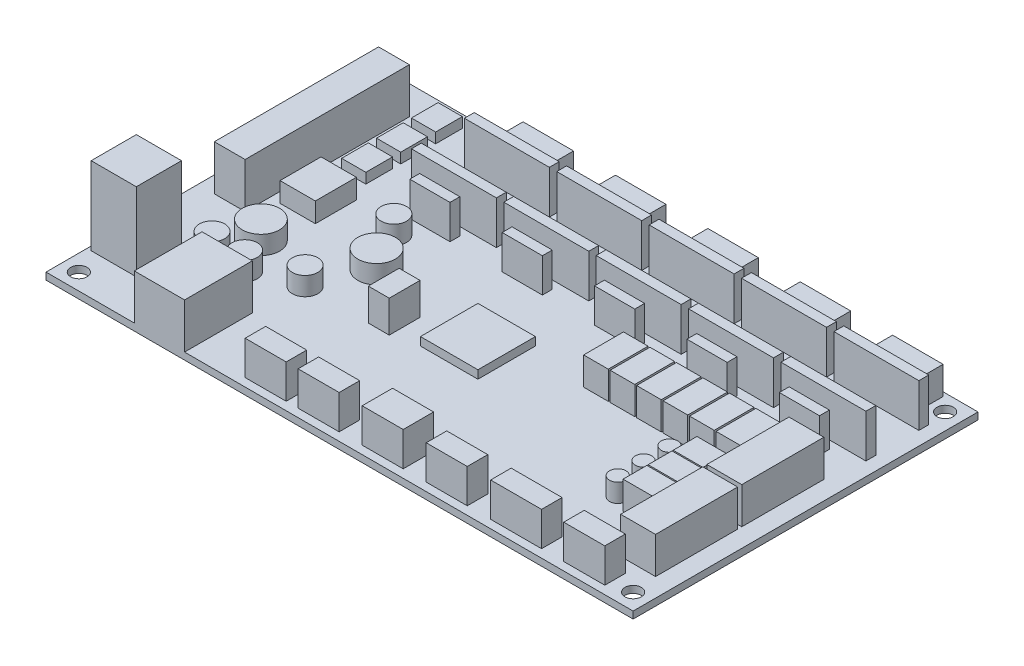
from build123d import *

# Parameters (mm, degrees)
PCB_W                     = 143
PCB_H                     = 84
PCB_R                     = 2
BOSS_PCB_DEPTH            = 1.7
BLUECONNECTOR_W           = 7.5
BLUECONNECTOR_H           = 40
BOSS_BLUECONNECTOR_DEPTH  = 11
GREENCONNECTOR_W          = 11
GREENCONNECTOR_H          = 11
BOSS_GREENCONNECTOR_DEPTH = 19
USB_W                     = 12.25
USB_H                     = 16.5
BOSS_USB_DEPTH            = 11
DRIVERSOCKETS_W           = 20.7
DRIVERSOCKETS_H           = 2.4
BOSS_DRIVERSOCKETS_DEPTH  = 10.5
NEMASOCKETS_W             = 12.3
NEMASOCKETS_H             = 5.7
BOSS_NEMASOCKETS_DEPTH    = 6.8
SKETCH2_W                 = 8.5
SKETCH2_H                 = 20
BOSS_EXTRUDE2_DEPTH       = 8.9
SKETCH3_W                 = 6
SKETCH3_H                 = 9.7
BOSS_EXTRUDE3_DEPTH       = 6.8
SKETCH4_W                 = 7.25
SKETCH4_H                 = 5.8
BOSS_EXTRUDE4_DEPTH       = 6.8
SKETCH5_R                 = 2
SKETCH5_R_2               = 3.1
SKETCH5_R_3               = 4.581614288
SKETCH5_R_4               = 4.548835819
BOSS_EXTRUDE5_DEPTH       = 4.5
SKETCH6_W                 = 5.9
SKETCH6_H                 = 6.5
BOSS_EXTRUDE6_DEPTH       = 2.5
SKETCH7_W                 = 8.6
SKETCH7_H                 = 10
BOSS_EXTRUDE7_DEPTH       = 4.8
SKETCH8_W                 = 5.1
SKETCH8_H                 = 7.5
BOSS_EXTRUDE8_DEPTH       = 7.8
SKETCH9_W                 = 14
SKETCH9_H                 = 14
BOSS_EXTRUDE9_DEPTH       = 2
SKETCH10_W                = 10
SKETCH10_H                = 5
SKETCH10_H_2              = 7.4
SKETCH10_W_2              = 12.4
BOSS_EXTRUDE10_DEPTH      = 8.3
SKETCH11_W                = 9.8
SKETCH11_H                = 2.4
BOSS_EXTRUDE11_DEPTH      = 8.3


with BuildPart() as part:
    # PCB → Boss-PCB (new body)
    with BuildSketch(Plane(origin=(0, 0, 0), x_dir=(1, 0, 0), z_dir=(0, 1, 0))):
        Rectangle(PCB_W, PCB_H)
        with Locations((-67.5, -38)):
            Circle(PCB_R, mode=Mode.SUBTRACT)
        with Locations((-67.5, 38)):
            Circle(PCB_R, mode=Mode.SUBTRACT)
        with Locations((67.5, -38)):
            Circle(PCB_R, mode=Mode.SUBTRACT)
        with Locations((67.5, 38)):
            Circle(PCB_R, mode=Mode.SUBTRACT)
    extrude(amount=BOSS_PCB_DEPTH)

    # BlueConnector → Boss-BlueConnector (add)
    with BuildSketch(Plane(origin=(0, 1.7, 0), x_dir=(1, 0, 0), z_dir=(0, 1, 0))):
        with Locations((-63.75, 15)):
            Rectangle(BLUECONNECTOR_W, BLUECONNECTOR_H)
    extrude(amount=BOSS_BLUECONNECTOR_DEPTH)

    # GreenConnector → Boss-GreenConnector (add)
    with BuildSketch(Plane(origin=(0, 1.7, 0), x_dir=(1, 0, 0), z_dir=(0, 1, 0))):
        with Locations((-65, -26.5)):
            Rectangle(GREENCONNECTOR_W, GREENCONNECTOR_H)
    extrude(amount=BOSS_GREENCONNECTOR_DEPTH)

    # Usb → Boss-Usb (add)
    with BuildSketch(Plane(origin=(0, 1.7, 0), x_dir=(1, 0, 0), z_dir=(0, 1, 0))):
        with Locations((-43.875, -33.75)):
            Rectangle(USB_W, USB_H)
    extrude(amount=BOSS_USB_DEPTH)

    # DriverSockets → Boss-DriverSockets (add)
    with BuildSketch(Plane(origin=(0, 1.7, 0), x_dir=(1, 0, 0), z_dir=(0, 1, 0))):
        with Locations((-32.15, 32.1)):
            Rectangle(DRIVERSOCKETS_W, DRIVERSOCKETS_H)
        with Locations((-32.15, 19.2)):
            Rectangle(DRIVERSOCKETS_W, DRIVERSOCKETS_H)
        with Locations((-9.65, 32.1)):
            Rectangle(DRIVERSOCKETS_W, DRIVERSOCKETS_H)
        with Locations((-9.65, 19.2)):
            Rectangle(DRIVERSOCKETS_W, DRIVERSOCKETS_H)
        with Locations((12.85, 32.1)):
            Rectangle(DRIVERSOCKETS_W, DRIVERSOCKETS_H)
        with Locations((12.85, 19.2)):
            Rectangle(DRIVERSOCKETS_W, DRIVERSOCKETS_H)
        with Locations((35.35, 32.1)):
            Rectangle(DRIVERSOCKETS_W, DRIVERSOCKETS_H)
        with Locations((35.35, 19.2)):
            Rectangle(DRIVERSOCKETS_W, DRIVERSOCKETS_H)
        with Locations((57.85, 32.1)):
            Rectangle(DRIVERSOCKETS_W, DRIVERSOCKETS_H)
        with Locations((57.85, 19.2)):
            Rectangle(DRIVERSOCKETS_W, DRIVERSOCKETS_H)
    extrude(amount=BOSS_DRIVERSOCKETS_DEPTH)

    # NemaSockets → Boss-NemaSockets (add)
    with BuildSketch(Plane(origin=(0, 1.7, 0), x_dir=(1, 0, 0), z_dir=(0, 1, 0))):
        with Locations((-32.15, 38.15)):
            Rectangle(NEMASOCKETS_W, NEMASOCKETS_H)
        with Locations((-9.65, 38.15)):
            Rectangle(NEMASOCKETS_W, NEMASOCKETS_H)
        with Locations((12.85, 38.15)):
            Rectangle(NEMASOCKETS_W, NEMASOCKETS_H)
        with Locations((35.35, 38.15)):
            Rectangle(NEMASOCKETS_W, NEMASOCKETS_H)
        with Locations((57.85, 38.15)):
            Rectangle(NEMASOCKETS_W, NEMASOCKETS_H)
    extrude(amount=BOSS_NEMASOCKETS_DEPTH)

    # Sketch2 → Boss-Extrude2 (add)
    with BuildSketch(Plane(origin=(0, 1.7, 0), x_dir=(1, 0, 0), z_dir=(0, 1, 0))):
        with Locations((62.711319294, -1)):
            Rectangle(SKETCH2_W, SKETCH2_H)
        with Locations((62.711319294, -22)):
            Rectangle(SKETCH2_W, SKETCH2_H)
    extrude(amount=BOSS_EXTRUDE2_DEPTH)

    # Sketch3 → Boss-Extrude3 (add)
    with BuildSketch(Plane(origin=(0, 1.7, 0), x_dir=(1, 0, 0), z_dir=(0, 1, 0))):
        with Locations((53.5, 4.05)):
            Rectangle(SKETCH3_W, SKETCH3_H)
        with Locations((47.05, 4.05)):
            Rectangle(SKETCH3_W, SKETCH3_H)
        with Locations((40.6, 4.05)):
            Rectangle(SKETCH3_W, SKETCH3_H)
        with Locations((34.15, 4.05)):
            Rectangle(SKETCH3_W, SKETCH3_H)
        with Locations((27.7, 4.05)):
            Rectangle(SKETCH3_W, SKETCH3_H)
        with Locations((21.25, 4.05)):
            Rectangle(SKETCH3_W, SKETCH3_H)
    extrude(amount=BOSS_EXTRUDE3_DEPTH)

    # Sketch4 → Boss-Extrude4 (add)
    with BuildSketch(Plane(origin=(0, 1.7, 0), x_dir=(1, 0, 0), z_dir=(0, 1, 0))):
        with Locations((52.875, -13.2)):
            Rectangle(SKETCH4_W, SKETCH4_H)
        with Locations((52.875, -7.1)):
            Rectangle(SKETCH4_W, SKETCH4_H)
        with Locations((52.875, -19.3)):
            Rectangle(SKETCH4_W, SKETCH4_H)
    extrude(amount=BOSS_EXTRUDE4_DEPTH)

    # Sketch5 → Boss-Extrude5 (add)
    with BuildSketch(Plane(origin=(0, 1.7, 0), x_dir=(1, 0, 0), z_dir=(0, 1, 0))):
        with Locations((45.532522997, -7.173614127)):
            Circle(SKETCH5_R)
        with Locations((45.532522997, -13.473614127)):
            Circle(SKETCH5_R)
        with Locations((45.532522997, -19.773614127)):
            Circle(SKETCH5_R)
        with Locations((-36.927915338, 8.153213954)):
            Circle(SKETCH5_R_2)
        with Locations((-55.386688385, -17.675511473)):
            Circle(SKETCH5_R_2)
        with Locations((-47.448627148, -17.675511473)):
            Circle(SKETCH5_R_2)
        with Locations((-36.927915338, -13.473614127)):
            Circle(SKETCH5_R_2)
        with Locations((-31.770956206, -1.204014924)):
            Circle(SKETCH5_R_3)
        with Locations((-52.013012359, -9.14208555)):
            Circle(SKETCH5_R_4)
    extrude(amount=BOSS_EXTRUDE5_DEPTH)

    # Sketch6 → Boss-Extrude6 (add)
    with BuildSketch(Plane(origin=(0, 1.7, 0), x_dir=(1, 0, 0), z_dir=(0, 1, 0))):
        with Locations((-54.05, 35.75)):
            Rectangle(SKETCH6_W, SKETCH6_H)
        with Locations((-54.05, 27.25)):
            Rectangle(SKETCH6_W, SKETCH6_H)
        with Locations((-54.05, 18.75)):
            Rectangle(SKETCH6_W, SKETCH6_H)
    extrude(amount=BOSS_EXTRUDE6_DEPTH)

    # Sketch7 → Boss-Extrude7 (add)
    with BuildSketch(Plane(origin=(0, 1.7, 0), x_dir=(1, 0, 0), z_dir=(0, 1, 0))):
        with Locations((-53.2, 6)):
            Rectangle(SKETCH7_W, SKETCH7_H)
    extrude(amount=BOSS_EXTRUDE7_DEPTH)

    # Sketch8 → Boss-Extrude8 (add)
    with BuildSketch(Plane(origin=(0, 1.7, 0), x_dir=(1, 0, 0), z_dir=(0, 1, 0))):
        with Locations((-18.95, -9.75)):
            Rectangle(SKETCH8_W, SKETCH8_H)
    extrude(amount=BOSS_EXTRUDE8_DEPTH)

    # Sketch9 → Boss-Extrude9 (add)
    with BuildSketch(Plane(origin=(0, 1.7, 0), x_dir=(1, 0, 0), z_dir=(0, 1, 0))):
        with Locations((-3.3, -5)):
            Rectangle(SKETCH9_W, SKETCH9_H)
    extrude(amount=BOSS_EXTRUDE9_DEPTH)

    # Sketch10 → Boss-Extrude10 (add)
    with BuildSketch(Plane(origin=(0, 1.7, 0), x_dir=(1, 0, 0), z_dir=(0, 1, 0))):
        with Locations((-20, -37.5)):
            Rectangle(SKETCH10_W, SKETCH10_H)
        with Locations((-7.1, -37.5)):
            Rectangle(SKETCH10_W, SKETCH10_H)
        with Locations((24.1, -37.5)):
            Rectangle(SKETCH10_W, SKETCH10_H)
        with Locations((8.5, -36.3)):
            Rectangle(SKETCH10_W, SKETCH10_H_2)
        with Locations((41, -37.5)):
            Rectangle(SKETCH10_W_2, SKETCH10_H)
        with Locations((57.6, -37.5)):
            Rectangle(SKETCH10_W, SKETCH10_H)
    extrude(amount=BOSS_EXTRUDE10_DEPTH)

    # Sketch11 → Boss-Extrude11 (add)
    with BuildSketch(Plane(origin=(0, 1.7, 0), x_dir=(1, 0, 0), z_dir=(0, 1, 0))):
        with Locations((-11.1, 14.8)):
            Rectangle(SKETCH11_W, SKETCH11_H)
        with Locations((-33.6, 14.8)):
            Rectangle(SKETCH11_W, SKETCH11_H)
        with Locations((11.4, 14.8)):
            Rectangle(SKETCH11_W, SKETCH11_H)
        with Locations((33.9, 14.8)):
            Rectangle(SKETCH11_W, SKETCH11_H)
        with Locations((56.4, 14.8)):
            Rectangle(SKETCH11_W, SKETCH11_H)
    extrude(amount=BOSS_EXTRUDE11_DEPTH)


solid = part.part
